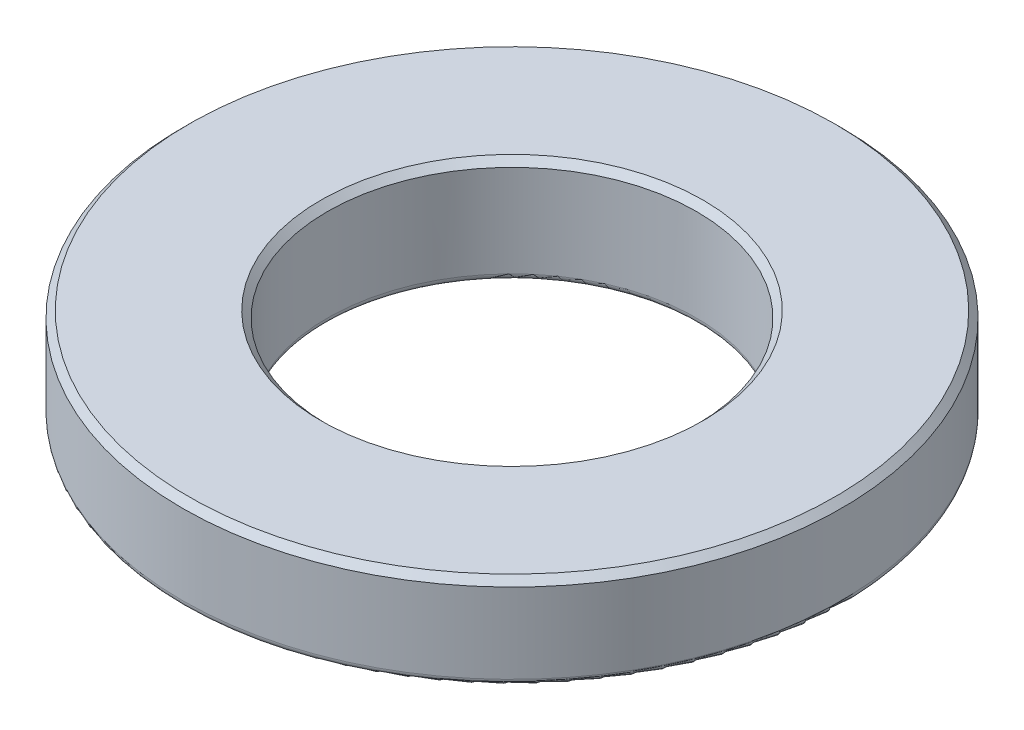
from build123d import *

# Parameters (mm, degrees)
CHAMFER1_SIZE = 0.254
FILLET4_R     = 0.254


with BuildPart() as part:
    # Sketch2 → Convex Revolve1 (revolve)
    with BuildSketch(Plane.XY, mode=Mode.PRIVATE) as convex_revolve1_sk:
        with BuildLine():
            Line((12.7, -102.362), (12.7, -105.921350067))
            ThreePointArc((12.7, -105.921350067), (9.909428815, -106.218763034), (7.112, -106.442669339))
            Line((7.112, -106.442669339), (7.112, -102.362))
            Line((7.112, -102.362), (12.7, -102.362))
        make_face()
    revolve(convex_revolve1_sk.sketch.rotate(Axis((0, 0, 0), (0, -1, 0)), 90), axis=Axis((0, 0, 0), (0, -1, 0)))  # turned: the seam where the file's is

    # Chamfer1
    chamfer1_edges = [part.edges().sort_by_distance(p)[0] for p in [
        (0, -102.362, -12.7),
        (0, -102.362, -7.112),
    ]]
    chamfer(chamfer1_edges, length=CHAMFER1_SIZE)

    # Fillet4
    fillet4_edges = [part.edges().sort_by_distance(p)[0] for p in [
        (0, -105.921350067, -12.7),
        (0, -106.442669339, -7.112),
    ]]
    fillet(fillet4_edges, radius=FILLET4_R)


solid = part.part
